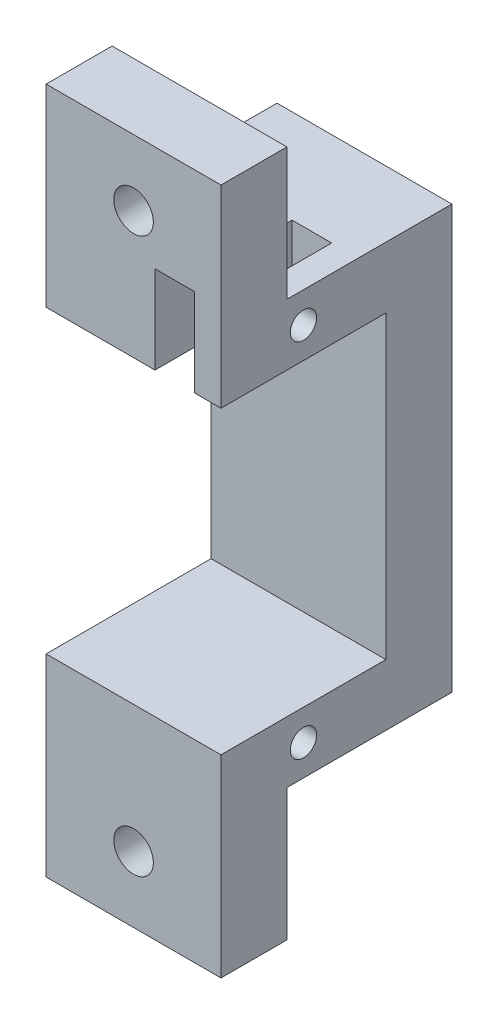
from build123d import *

# Parameters (mm, degrees)
ESBO_O1_W                = 13.25
ESBO_O1_H                = 12.5
RESSALTO_EXTRUS_O1_DEPTH = 4.65
ESBO_O2_W                = 13.25
ESBO_O2_H                = 32.05
RESSALTO_EXTRUS_O2_DEPTH = 5
ESBO_O3_W                = 13.25
ESBO_O3_H                = 4.65
RESSALTO_EXTRUS_O3_DEPTH = 12.5
ESBO_O4_W                = 13.25
ESBO_O4_H                = 5
RESSALTO_EXTRUS_O4_DEPTH = 10
ESBO_O5_W                = 13.25
ESBO_O5_H                = 5
RESSALTO_EXTRUS_O5_DEPTH = 10
ESBO_O6_R                = 1.5
CORTE_EXTRUS_O1_DEPTH    = 10
ESBO_O7_R                = 1
CORTE_EXTRUS_O2_DEPTH    = 14.25
ESBO_O8_R                = 1
CORTE_EXTRUS_O3_DEPTH    = 14.25
ESBO_O9_W                = 3
ESBO_O9_H                = 10.390977072
CORTE_EXTRUS_O4_DEPTH    = 10
ESBO_O10_W               = 3
ESBO_O10_H               = 2
CORTE_EXTRUS_O5_DEPTH    = 10


with BuildPart() as part:
    # Esboço1 → Ressalto-extrusão1 (new body)
    with BuildSketch(Plane(origin=(0, 0, 0), x_dir=(1, 0, 0), z_dir=(0, 1, 0))):
        with Locations((-15.112918198, -12.411797698)):
            Rectangle(ESBO_O1_W, ESBO_O1_H)
    extrude(amount=-RESSALTO_EXTRUS_O1_DEPTH)

    # Esboço2 → Ressalto-extrusão2 (add)
    with BuildSketch(Plane(origin=(0, 0, 6.161797698), x_dir=(-1, 0, 0), z_dir=(0, 0, -1))):
        with Locations((15.112918198, -16.025)):
            Rectangle(ESBO_O2_W, ESBO_O2_H)
    extrude(amount=RESSALTO_EXTRUS_O2_DEPTH)

    # Esboço3 → Ressalto-extrusão3 (add)
    with BuildSketch(Plane.XY.offset(6.161797698)):
        with Locations((-15.112918198, -29.725)):
            Rectangle(ESBO_O3_W, ESBO_O3_H)
    extrude(amount=RESSALTO_EXTRUS_O3_DEPTH)

    # Esboço4 → Ressalto-extrusão4 (add)
    with BuildSketch(Plane(origin=(0, -32.05, 0), x_dir=(-1, 0, 0), z_dir=(0, -1, 0))):
        with Locations((15.112918198, -16.161797698)):
            Rectangle(ESBO_O4_W, ESBO_O4_H)
    extrude(amount=RESSALTO_EXTRUS_O4_DEPTH)

    # Esboço5 → Ressalto-extrusão5 (add)
    with BuildSketch(Plane(origin=(0, 0, 0), x_dir=(1, 0, 0), z_dir=(0, 1, 0))):
        with Locations((-15.112918198, -16.161797698)):
            Rectangle(ESBO_O5_W, ESBO_O5_H)
    extrude(amount=RESSALTO_EXTRUS_O5_DEPTH)

    # Esboço6 → Corte-extrusão1 (cut)
    with BuildSketch(Plane(origin=(0, 0, 13.661797698), x_dir=(-1, 0, 0), z_dir=(0, 0, -1))):
        with Locations((15.112918198, 5)):
            Circle(ESBO_O6_R)
        with Locations((15.112918198, -37.05)):
            Circle(ESBO_O6_R)
    extrude(amount=-CORTE_EXTRUS_O1_DEPTH, mode=Mode.SUBTRACT)

    # Esboço7 → Corte-extrusão2 (cut, through all)
    with BuildSketch(Plane(origin=(-8.487918198, 0, 0), x_dir=(0, 0, -1), z_dir=(1, 0, 0))):
        with Locations((-12.411797698, -2.325)):
            Circle(ESBO_O7_R)
    extrude(amount=-CORTE_EXTRUS_O2_DEPTH, mode=Mode.SUBTRACT)

    # Esboço8 → Corte-extrusão3 (cut, through all)
    with BuildSketch(Plane(origin=(-8.487918198, 0, 0), x_dir=(0, 0, -1), z_dir=(1, 0, 0))):
        with Locations((-12.411797698, -29.725)):
            Circle(ESBO_O8_R)
    extrude(amount=-CORTE_EXTRUS_O3_DEPTH, mode=Mode.SUBTRACT)

    # Esboço9 → Corte-extrusão4 (cut)
    with BuildSketch(Plane(origin=(0, 0, 0), x_dir=(1, 0, 0), z_dir=(0, 1, 0))):
        with Locations((-11.987918198, -13.466309162)):
            Rectangle(ESBO_O9_W, ESBO_O9_H)
    extrude(amount=-CORTE_EXTRUS_O4_DEPTH, mode=Mode.SUBTRACT)

    # Esboço10 → Corte-extrusão5 (cut)
    with BuildSketch(Plane(origin=(0, 0, 13.661797698), x_dir=(-1, 0, 0), z_dir=(0, 0, -1))):
        with Locations((11.987918198, 1)):
            Rectangle(ESBO_O10_W, ESBO_O10_H)
    extrude(amount=-CORTE_EXTRUS_O5_DEPTH, mode=Mode.SUBTRACT)


solid = part.part
